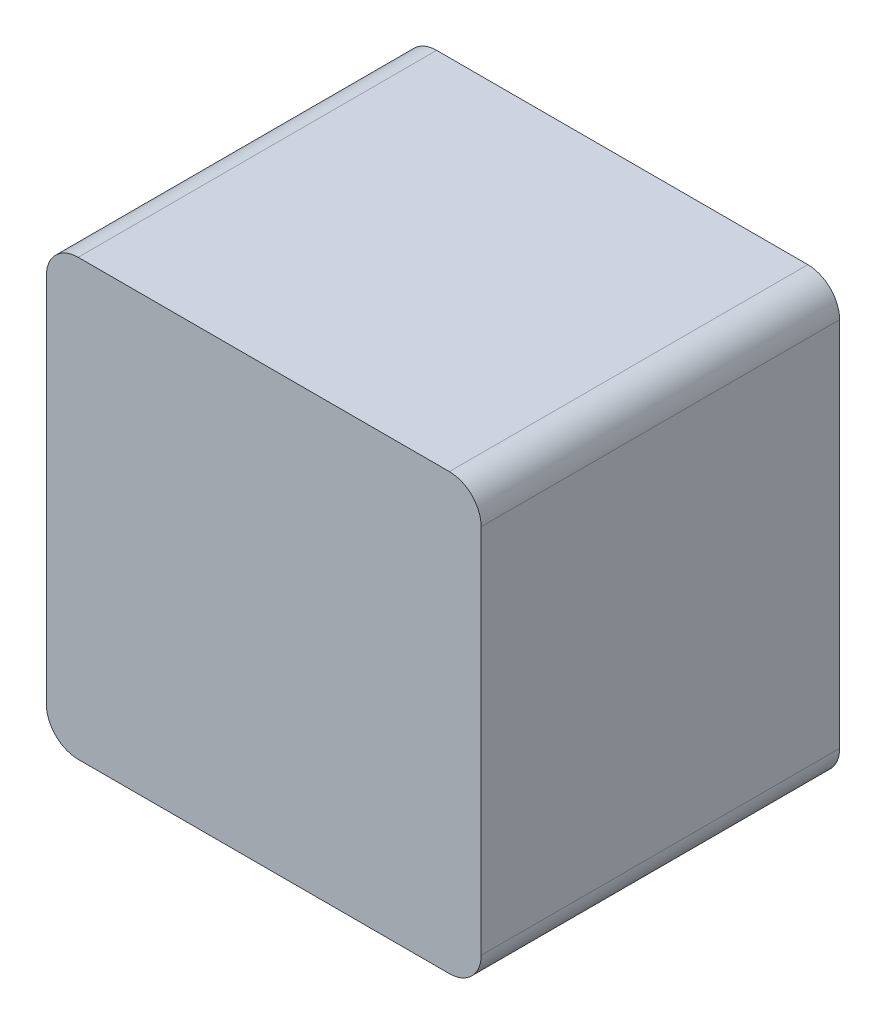
from build123d import *

# Parameters (mm, degrees)
SKETCH1_W           = 41
SKETCH1_H           = 41
BOSS_EXTRUDE1_DEPTH = 33.8
SKETCH2_R           = 5
SKETCH2_R_2         = 4.9
BOSS_EXTRUDE2_DEPTH = 15
FILLET1_R           = 3


with BuildPart() as part:
    # Sketch1 → Boss-Extrude1 (new body)
    with BuildSketch(Plane.XY):
        with Locations((54.5, -202.5)):
            Rectangle(SKETCH1_W, SKETCH1_H)
    extrude(amount=BOSS_EXTRUDE1_DEPTH)

    # Fillet1
    fillet1_edges = [part.edges().sort_by_distance(p)[0] for p in [
        (34, -223, 16.9),
        (34, -182, 16.9),
        (75, -182, 16.9),
        (75, -223, 16.9),
    ]]
    fillet(fillet1_edges, radius=FILLET1_R)


with BuildPart() as body_2:
    # Sketch2 → Boss-Extrude2 (new body)
    with BuildSketch(Plane(origin=(0, 0, 0), x_dir=(-1, 0, 0), z_dir=(0, 0, -1))):
        with Locations((-54.5, -202.5)):
            Circle(SKETCH2_R)
        with Locations((-54.5, -202.5)):
            Circle(SKETCH2_R_2, mode=Mode.SUBTRACT)
    extrude(amount=BOSS_EXTRUDE2_DEPTH)


solid = Compound([part.part, body_2.part])
